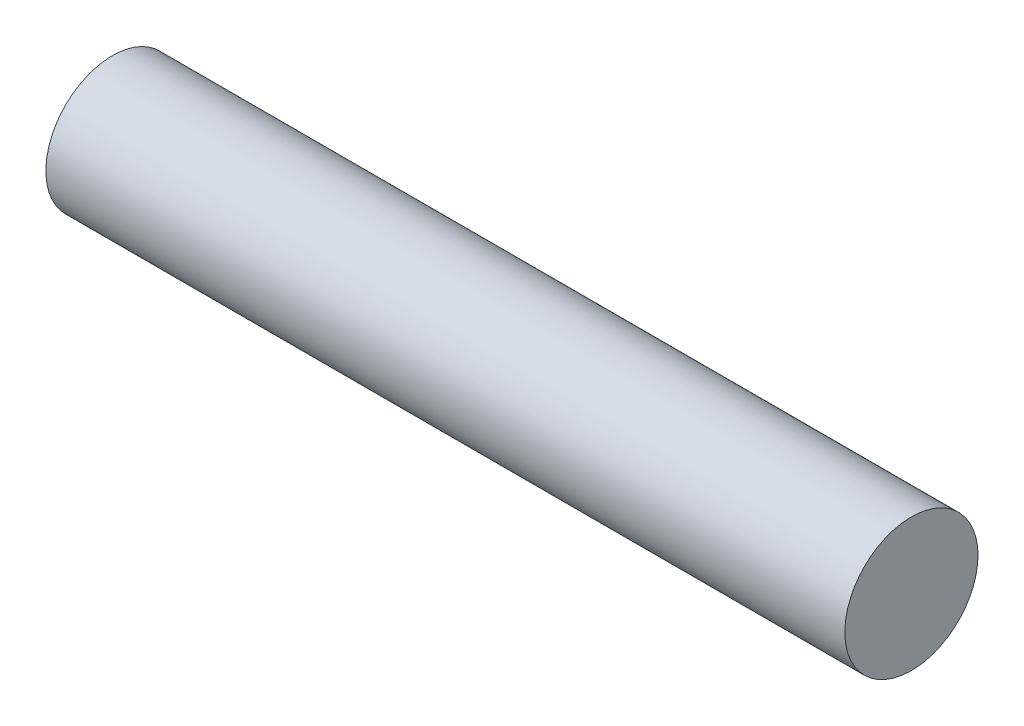
from build123d import *

# Parameters (mm, degrees)
SKETCH1_R           = 6.35
BOSS_EXTRUDE1_DEPTH = 76.2


with BuildPart() as part:
    # Sketch1 → Boss-Extrude1 (new body)
    with BuildSketch(Plane(origin=(0, 0, 0), x_dir=(0, 0, -1), z_dir=(1, 0, 0))):
        Circle(SKETCH1_R)
    extrude(amount=BOSS_EXTRUDE1_DEPTH)


solid = part.part
